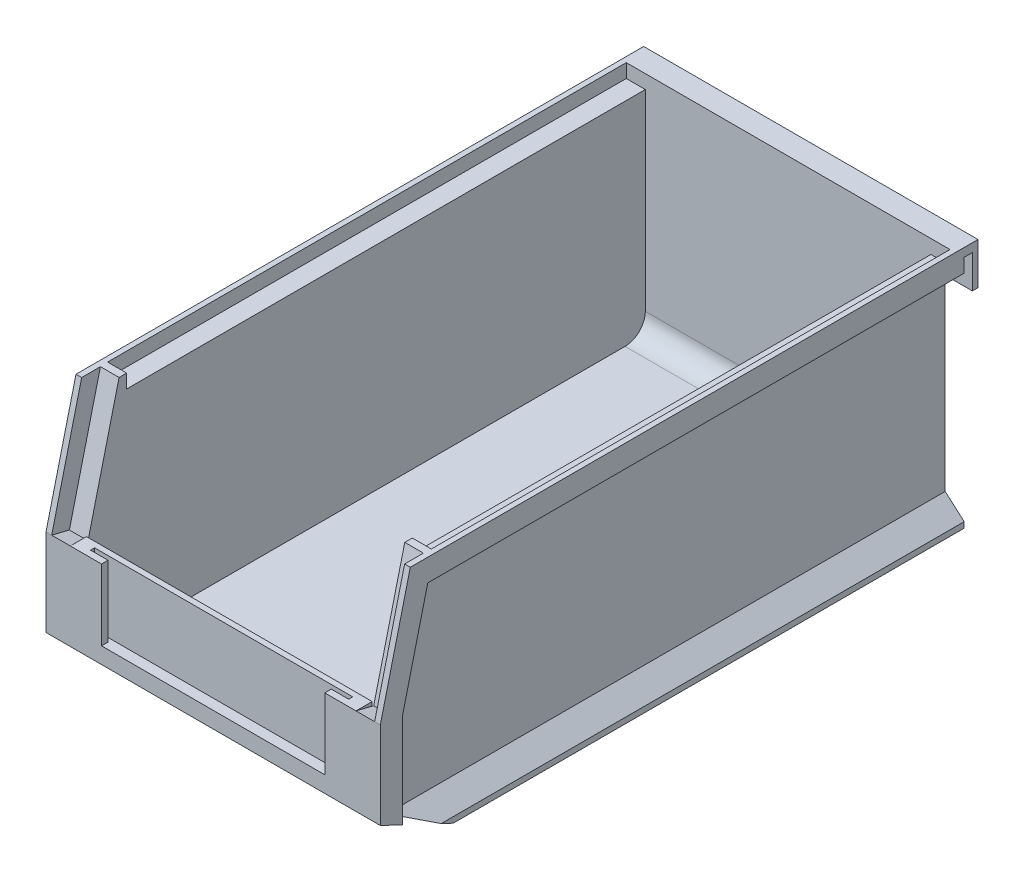
from build123d import *

# Parameters (mm, degrees)
SKETCH1_W                       = 104.775
SKETCH1_H                       = 76.2
BOSS_EXTRUDE1_DEPTH             = 187.325
CUT_EXTRUDE1_REACH              = 106.775
SKETCH3_W                       = 101.473
SKETCH3_H                       = 162.56
CUT_EXTRUDE2_DEPTH              = 4.318
SKETCH4_W                       = 89.535
SKETCH4_H                       = 175.133
CUT_EXTRUDE3_DEPTH              = 66.548
CUT_EXTRUDE3_DIRECTION_2_REACH  = 6.318
SKETCH5_W                       = 89.535
SKETCH5_H                       = 15.113
CUT_EXTRUDE4_DEPTH              = 38.1
CUT_EXTRUDE5_DEPTH              = 105.775
SKETCH7_W                       = 5.842
SKETCH7_H                       = 43.18
CUT_EXTRUDE6_DEPTH              = 5.715
CUT_EXTRUDE7_DEPTH              = 22.225
BOSS_EXTRUDE2_REACH             = 54.388
BOSS_EXTRUDE2_DIRECTION_2_REACH = 54.387
CUT_EXTRUDE8_DEPTH              = 104.775
CUT_EXTRUDE9_DEPTH              = 5.969
SKETCH12_W                      = 86.995
SKETCH12_H                      = 164.98932792
CUT_EXTRUDE10_DEPTH             = 2.921
CUT_EXTRUDE11_DEPTH             = 184.007
FILLET1_R                       = 6.35


with BuildPart() as part:
    # Sketch1 → Boss-Extrude1 (new body)
    with BuildSketch(Plane.XY):
        with Locations((52.3875, 38.1)):
            Rectangle(SKETCH1_W, SKETCH1_H)
    extrude(amount=BOSS_EXTRUDE1_DEPTH)

    # Sketch2 → Cut-Extrude1 (cut, up to next)
    with BuildSketch(Plane(origin=(104.775, 0, 0), x_dir=(0, 0, -1), z_dir=(1, 0, 0)), mode=Mode.PRIVATE) as cut_extrude1_sk1:
        Polygon((0, 0), (-4.318, 0), (-4.318, 73.533), (-1.778, 73.533), (-1.778, 63.119), (0, 63.119), align=None)
    cut_extrude1_tool1 = extrude(cut_extrude1_sk1.sketch, amount=-CUT_EXTRUDE1_REACH, mode=Mode.PRIVATE) & part.part
    add(cut_extrude1_tool1.solids().sort_by_distance((104.775, 34.812119, 2.237647))[0], mode=Mode.SUBTRACT)

    # Sketch3 → Cut-Extrude2 (cut)
    with BuildSketch(Plane(origin=(0, 76.2, 0), x_dir=(1, 0, 0), z_dir=(0, 1, 0))):
        with Locations((52.3875, -88.392)):
            Rectangle(SKETCH3_W, SKETCH3_H)
    extrude(amount=-CUT_EXTRUDE2_DEPTH, mode=Mode.SUBTRACT)

    # Sketch4 → Cut-Extrude3 (cut)
    with BuildSketch(Plane(origin=(0, 71.882, 0), x_dir=(1, 0, 0), z_dir=(0, 1, 0))):
        with Locations((52.3875, -94.6785)):
            Rectangle(SKETCH4_W, SKETCH4_H)
    extrude(amount=-CUT_EXTRUDE3_DEPTH, mode=Mode.SUBTRACT)

    # Sketch4 → Cut-Extrude3 direction 2 (cut, up to next)
    with BuildSketch(Plane(origin=(0, 71.882, 0), x_dir=(1, 0, 0), z_dir=(0, 1, 0)), mode=Mode.PRIVATE) as cut_extrude3_direction_2_sk1:
        with Locations((52.3875, -94.6785)):
            Rectangle(SKETCH4_W, SKETCH4_H)
    cut_extrude3_direction_2_tool1 = extrude(cut_extrude3_direction_2_sk1.sketch, amount=CUT_EXTRUDE3_DIRECTION_2_REACH, mode=Mode.PRIVATE) & part.part
    add(cut_extrude3_direction_2_tool1.solids().sort_by_distance((52.3875, 71.882, 94.6785))[0], mode=Mode.SUBTRACT)

    # Sketch5 → Cut-Extrude4 (cut)
    with BuildSketch(Plane(origin=(0, 76.2, 0), x_dir=(1, 0, 0), z_dir=(0, 1, 0))):
        with Locations((52.3875, -179.7685)):
            Rectangle(SKETCH5_W, SKETCH5_H)
    extrude(amount=-CUT_EXTRUDE4_DEPTH, mode=Mode.SUBTRACT)

    # Sketch6 → Cut-Extrude5 (cut, through all)
    with BuildSketch(Plane.ZY):
        Polygon((187.325, 38.1), (187.325, 76.2), (177.927, 76.2), align=None)
    extrude(amount=-CUT_EXTRUDE5_DEPTH, mode=Mode.SUBTRACT)

    # Sketch7 → Cut-Extrude6 (cut)
    with BuildSketch(Plane(origin=(0, 45.741868113, 185.440005865), x_dir=(1, 0, 0), z_dir=(0, 0.239488471, 0.970899208))):
        with Locations((4.699, 13.719081937)):
            Rectangle(SKETCH7_W, SKETCH7_H)
        with Locations((100.076, 13.719081937)):
            Rectangle(SKETCH7_W, SKETCH7_H)
    extrude(amount=-CUT_EXTRUDE6_DEPTH, mode=Mode.SUBTRACT)

    # Sketch8 → Cut-Extrude7 (cut)
    with BuildSketch(Plane(origin=(0, 38.1, 0), x_dir=(1, 0, 0), z_dir=(0, 1, 0))):
        Polygon((92.837, -184.023), (11.938, -184.023), (11.938, -185.293), (17.399, -185.293), (17.399, -187.325), (87.376, -187.325), (87.376, -185.293), (92.837, -185.293), align=None)
    extrude(amount=-CUT_EXTRUDE7_DEPTH, mode=Mode.SUBTRACT)

    # Boss-Extrude2: up to this face of the body (flat: up to its plane)
    boss_extrude2_end = Plane(part.part.faces().sort_by_distance((97.155, 38.338270724, 93.520892383))[0])
    # Sketch9 → Boss-Extrude2 (add, up to the picked face)
    with BuildSketch(Plane(origin=(52.3875, 0, 0), x_dir=(0, 0, -1), z_dir=(1, 0, 0)), mode=Mode.PRIVATE) as boss_extrude2_sk1:
        Polygon((-156.845, 5.334), (-182.245, 5.334), (-182.245, 27.448933333), align=None)
    boss_extrude2_tool1 = split(extrude(boss_extrude2_sk1.sketch, amount=BOSS_EXTRUDE2_REACH, mode=Mode.PRIVATE), bisect_by=boss_extrude2_end, keep=Keep.BOTH, mode=Mode.PRIVATE)
    add(boss_extrude2_tool1.solids().sort_by_distance((52.3875, 12.705644, 173.778333))[0])

    # Boss-Extrude2 direction 2: up to this face of the body (flat: up to its plane)
    boss_extrude2_direction_2_end = Plane(part.part.faces().sort_by_distance((7.62, 38.338270724, 93.520892383))[0])
    # Sketch9 → Boss-Extrude2 direction 2 (add, up to the picked face)
    with BuildSketch(Plane(origin=(52.3875, 0, 0), x_dir=(0, 0, -1), z_dir=(1, 0, 0)), mode=Mode.PRIVATE) as boss_extrude2_direction_2_sk1:
        Polygon((-156.845, 5.334), (-182.245, 5.334), (-182.245, 27.448933333), align=None)
    boss_extrude2_direction_2_tool1 = split(extrude(boss_extrude2_direction_2_sk1.sketch, amount=-BOSS_EXTRUDE2_DIRECTION_2_REACH, mode=Mode.PRIVATE), bisect_by=boss_extrude2_direction_2_end, keep=Keep.BOTH, mode=Mode.PRIVATE)
    add(boss_extrude2_direction_2_tool1.solids().sort_by_distance((52.3875, 12.705644, 173.778333))[0])

    # Sketch10 → Cut-Extrude8 (cut)
    with BuildSketch(Plane(origin=(104.775, 0, 0), x_dir=(0, 0, -1), z_dir=(1, 0, 0))):
        Polygon((-187.325, 10.795), (-187.325, 0), (-164.465, 0), align=None)
    extrude(amount=-CUT_EXTRUDE8_DEPTH, mode=Mode.SUBTRACT)

    # Sketch11 → Cut-Extrude9 (cut)
    with BuildSketch(Plane.ZY):
        Polygon((110.611802523, 69.215), (4.318, 69.215), (4.318, 6.985), (180.34, 6.985), (180.34, 37.251236671), (172.455605046, 69.215), align=None)
    cut_extrude9 = extrude(amount=-CUT_EXTRUDE9_DEPTH, mode=Mode.SUBTRACT)

    # Mirror1: Cut-Extrude9 across plane
    add(cut_extrude9.mirror(Plane(origin=(52.3875, 0, 0), x_dir=(0, 0, 1), z_dir=(1, 0, 0))), mode=Mode.SUBTRACT)

    # Sketch12 → Cut-Extrude10 (cut)
    with BuildSketch(Plane.XZ):
        with Locations((52.3875, 86.81266396)):
            Rectangle(SKETCH12_W, SKETCH12_H)
    extrude(amount=-CUT_EXTRUDE10_DEPTH, mode=Mode.SUBTRACT)

    # Sketch13 → Cut-Extrude11 (cut, through all)
    with BuildSketch(Plane(origin=(0, 0, 4.318), x_dir=(-1, 0, 0), z_dir=(0, 0, -1))):
        Polygon((-5.969, 6.985), (0, 6.985), (0, 1.778), align=None)
        Polygon((-98.806, 6.985), (-104.775, 6.985), (-104.775, 1.778), align=None)
    extrude(amount=-CUT_EXTRUDE11_DEPTH, mode=Mode.SUBTRACT)

    # Fillet1
    fillet1_edges = [part.edges().sort_by_distance(p)[0] for p in [
        (52.3875, 5.334, 7.112),
        (52.3875, 5.334, 156.845),
    ]]
    fillet(fillet1_edges, radius=FILLET1_R)


solid = part.part
